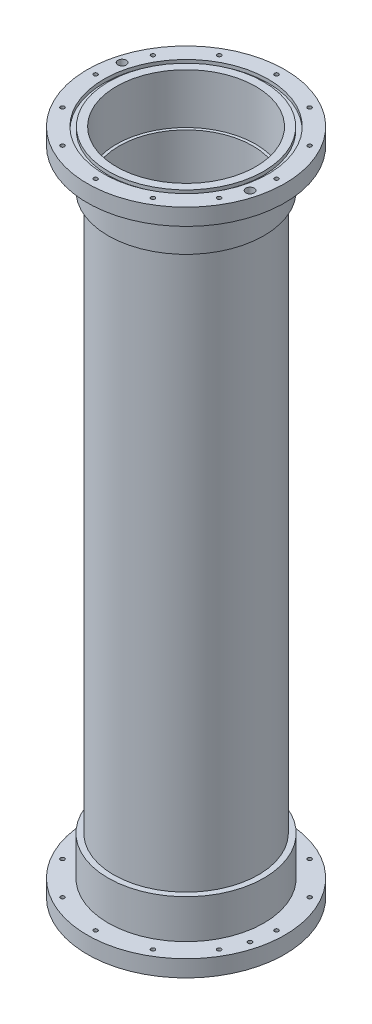
from build123d import *

# Parameters (mm, degrees)
SKETCH2_R               = 41.275
SKETCH2_R_2             = 38.1
BASE_CYLINDER_DEPTH     = 381
SKETCH3_R               = 56.35625
SKETCH3_R_2             = 38.1
AFT_FLANGE_DEPTH        = 9.525
SKETCH34_R              = 39.75
TEMPERATUREINSERT_DEPTH = 28.575
SKETCH6_R               = 46.9011
SKETCH6_R_2             = 44.2849
AFT_O_RING_DEPTH        = 1.9812
SKETCH33_R              = 44.45
SKETCH33_R_2            = 41.275
CRITICALBOSS_DEPTH      = 22.225
BOLT_CIRCLE_D           = 2.2606
BOLT_CIRCLE_DEPTH       = 381
HOLE1_D                 = 2.38125
HOLE1_DEPTH             = 381
HOLE1_CBORE_D           = 4.7625
HOLE1_CBORE_DEPTH       = 4.7625


with BuildPart() as part:
    # Sketch2 → Base Cylinder (new body)
    with BuildSketch(Plane(origin=(0, 0, 0), x_dir=(1, 0, 0), z_dir=(0, 1, 0))):
        Circle(SKETCH2_R)
        Circle(SKETCH2_R_2, mode=Mode.SUBTRACT)
    extrude(amount=BASE_CYLINDER_DEPTH)

    # Sketch3 → Aft Flange (add)
    with BuildSketch(Plane.XZ):
        Circle(SKETCH3_R)
        Circle(SKETCH3_R_2, mode=Mode.SUBTRACT)
    aft_flange = extrude(amount=-AFT_FLANGE_DEPTH)

    # Sketch34 → TemperatureInsert (cut)
    with BuildSketch(Plane.XZ):
        Circle(SKETCH34_R)
    temperatureinsert = extrude(amount=-TEMPERATUREINSERT_DEPTH, mode=Mode.SUBTRACT)

    # Sketch6 → Aft O-Ring (cut)
    with BuildSketch(Plane.XZ):
        Circle(SKETCH6_R)
        Circle(SKETCH6_R_2, mode=Mode.SUBTRACT)
    aft_o_ring = extrude(amount=-AFT_O_RING_DEPTH, mode=Mode.SUBTRACT)

    # Sketch33 → CriticalBoss (add)
    with BuildSketch(Plane(origin=(0, 9.525, 0), x_dir=(1, 0, 0), z_dir=(0, 1, 0))):
        Circle(SKETCH33_R)
        Circle(SKETCH33_R_2, mode=Mode.SUBTRACT)
    criticalboss = extrude(amount=CRITICALBOSS_DEPTH)

    # Bolt Circle
    with Locations(Plane(origin=(0, 0, 0), x_dir=(-1, 0, 0), z_dir=(0, -1, 0))):
        with Locations((-25.81275, -44.708994483), (-44.708994483, -25.81275), (-51.6255, 0), (-44.708994483, 25.81275), (-25.81275, 44.708994483), (0, 51.6255), (25.81275, 44.708994483), (44.708994483, 25.81275), (51.6255, 0), (44.708994483, -25.81275), (25.81275, -44.708994483), (0, -51.6255)):
            bolt_circle = Hole(BOLT_CIRCLE_D / 2, depth=BOLT_CIRCLE_DEPTH)

    # Hole1
    with Locations(Plane(origin=(0, 0, 0), x_dir=(-1, 0, 0), z_dir=(0, -1, 0))):
        with Locations((49.866403745, 13.361662613), (-49.866403745, -13.361662613)):
            hole1 = CounterBoreHole(HOLE1_D / 2, HOLE1_CBORE_D / 2, HOLE1_CBORE_DEPTH, depth=HOLE1_DEPTH)

    # Mirror1: Aft Flange, TemperatureInsert, Aft O-Ring, CriticalBoss, Bolt Circle, Hole1 across plane
    add(aft_flange.mirror(Plane.ZX.offset(190.5)))
    add(temperatureinsert.mirror(Plane.ZX.offset(190.5)), mode=Mode.SUBTRACT)
    add(aft_o_ring.mirror(Plane.ZX.offset(190.5)), mode=Mode.SUBTRACT)
    add(criticalboss.mirror(Plane.ZX.offset(190.5)))
    add(bolt_circle.mirror(Plane.ZX.offset(190.5)), mode=Mode.SUBTRACT)
    add(hole1.mirror(Plane.ZX.offset(190.5)), mode=Mode.SUBTRACT)


solid = part.part
